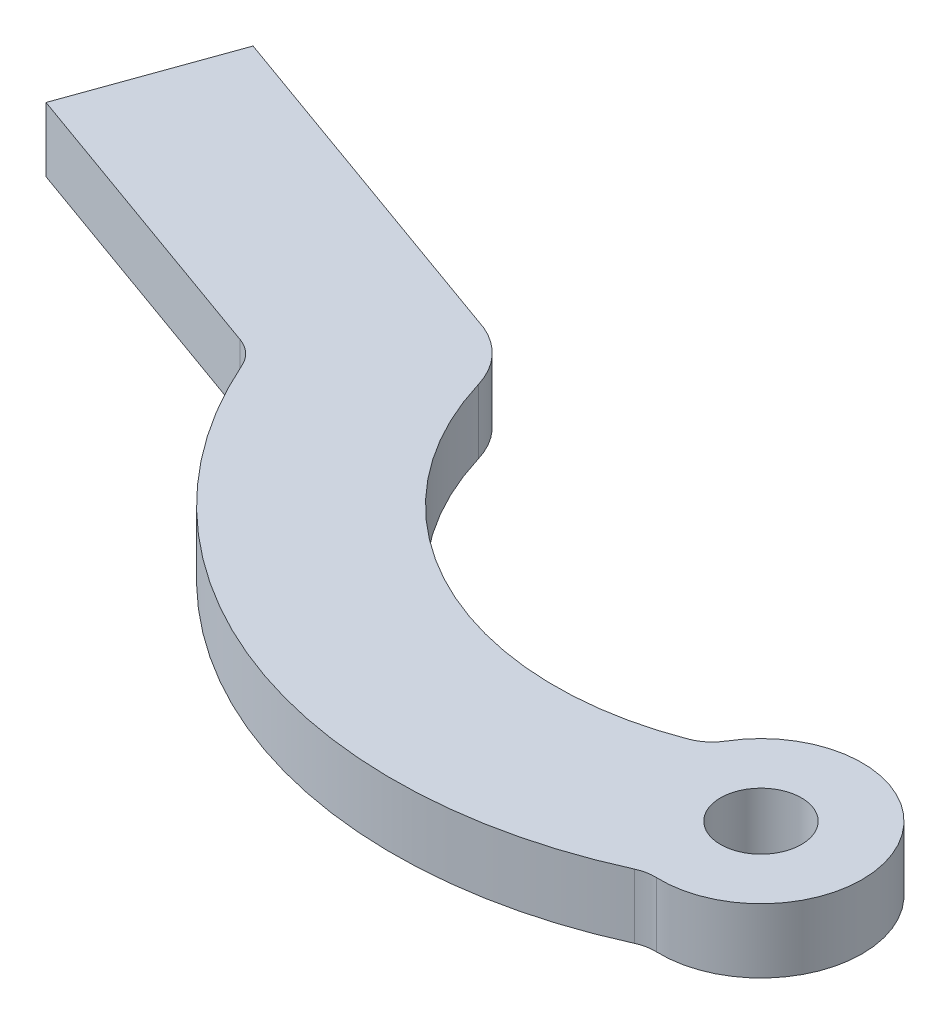
from build123d import *

# Parameters (mm, degrees)
SKETCH1_R           = 1
BOSS_EXTRUDE1_DEPTH = 1.59


with BuildPart() as part:
    # Sketch1 → Boss-Extrude1 (new body)
    with BuildSketch(Plane(origin=(0, 0, 0), x_dir=(1, 0, 0), z_dir=(0, 1, 0))):
        with BuildLine():
            Line((-13.982567653, 7.132116323), (-22.861764958, 10.312114381))
            Line((-22.861764958, 10.312114381), (-24.21044114, 6.546337894))
            Line((-24.21044114, 6.546337894), (-16.738208265, 3.870230446))
            ThreePointArc((-16.738208265, 3.870230446), (-16.394250173, 3.660951485), (-16.160706095, 3.332984998))
            ThreePointArc((-16.160706095, 3.332984998), (-9.589384902, -2.894483489), (-0.541170736, -2.5887935))
            ThreePointArc((-0.541170736, -2.5887935), (-0.320283974, -2.517169363), (-0.088833144, -2.498421236))
            ThreePointArc((-0.088833144, -2.498421236), (2.19617582, 1.194492264), (-2.145600439, 1.283120709))
            ThreePointArc((-2.145600439, 1.283120709), (-2.359359709, 1.03174859), (-2.643290683, 0.863629079))
            ThreePointArc((-2.643290683, 0.863629079), (-8.831767295, 1.131940065), (-12.836874427, 5.857228461))
            ThreePointArc((-12.836874427, 5.857228461), (-13.266784954, 6.623123616), (-13.982567653, 7.132116323))
        make_face()
        Circle(SKETCH1_R, mode=Mode.SUBTRACT)
    extrude(amount=BOSS_EXTRUDE1_DEPTH)


solid = part.part
